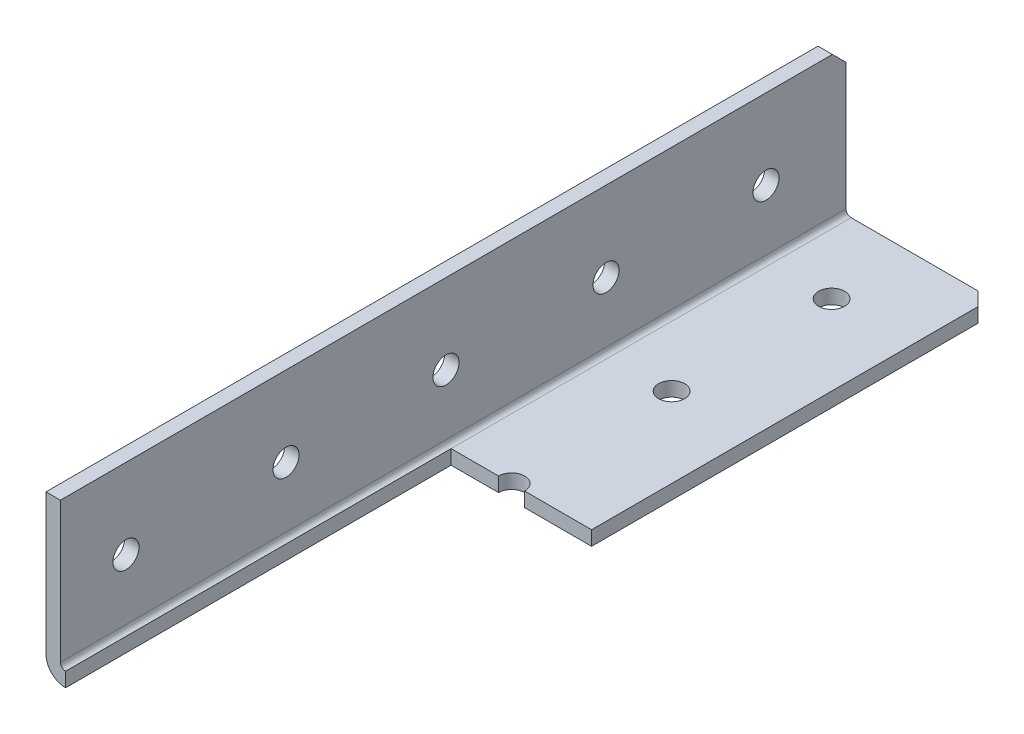
from build123d import *

# Parameters (mm, degrees)
SKETCH1_W                  = 25.4
SKETCH1_H                  = 1498.6
BOSS_EXTRUDE1_DEPTH        = 25.4
SKETCH2_W                  = 23.114
SKETCH2_H                  = 23.114
CUT_EXTRUDE1_DEPTH         = 1499.6
M3_5_CLEARANCE_HOLE1_D     = 4.1402
M3_5_CLEARANCE_HOLE1_DEPTH = 25.4
M3_5_CLEARANCE_HOLE2_D     = 4.1402
M3_5_CLEARANCE_HOLE2_DEPTH = 25.4
CHAMFER1_SIZE              = 2.159
FILLET1_R                  = 0.8128
FILLET2_R                  = 3.0988
SKETCH8_W                  = 95.882963774
SKETCH8_H                  = 79.338329604
CUT_EXTRUDE3_DEPTH         = 1371.6
SKETCH11_W                 = 51.462522779
SKETCH11_H                 = 66.676735099
CUT_EXTRUDE6_DEPTH         = 2.286
SKETCH12_W                 = 22.3012
SKETCH12_H                 = 61.214
CUT_EXTRUDE7_DEPTH         = 2.54


with BuildPart() as part:
    # Sketch1 → Boss-Extrude1 (new body)
    with BuildSketch(Plane(origin=(0, 0, 0), x_dir=(0, -1, 0), z_dir=(-1, 0, 0))):
        with Locations((-12.7, 0)):
            Rectangle(SKETCH1_W, SKETCH1_H)
    extrude(amount=-BOSS_EXTRUDE1_DEPTH)

    # Sketch2 → Cut-Extrude1 (cut, through all)
    with BuildSketch(Plane(origin=(0, 0, -749.3), x_dir=(-1, 0, 0), z_dir=(0, 0, -1))):
        with Locations((-13.843, 13.843)):
            Rectangle(SKETCH2_W, SKETCH2_H)
    extrude(amount=-CUT_EXTRUDE1_DEPTH, mode=Mode.SUBTRACT)

    # M3.5 Clearance Hole1
    with Locations(Plane(origin=(0, 0, 0), x_dir=(-1, 0, 0), z_dir=(0, -1, 0))):
        with Locations((-12.7, 736.6), (-12.7, 711.2), (-12.7, 685.8), (-12.7, 660.4), (-12.7, 635), (-12.7, 609.6), (-12.7, 584.2), (-12.7, 558.8), (-12.7, 533.4), (-12.7, 508), (-12.7, 482.6), (-12.7, 457.2), (-12.7, 431.8), (-12.7, 406.4), (-12.7, 381), (-12.7, 355.6), (-12.7, 330.2), (-12.7, 304.8), (-12.7, 279.4), (-12.7, 254), (-12.7, 228.6), (-12.7, 203.2), (-12.7, 177.8), (-12.7, 152.4), (-12.7, 127), (-12.7, 101.6), (-12.7, 76.2), (-12.7, 50.8), (-12.7, 25.4), (-12.7, 0), (-12.7, -25.4), (-12.7, -50.8), (-12.7, -76.2), (-12.7, -101.6), (-12.7, -127), (-12.7, -152.4), (-12.7, -177.8), (-12.7, -203.2), (-12.7, -228.6), (-12.7, -254), (-12.7, -279.4), (-12.7, -304.8), (-12.7, -330.2), (-12.7, -355.6), (-12.7, -381), (-12.7, -406.4), (-12.7, -431.8), (-12.7, -457.2), (-12.7, -482.6), (-12.7, -508), (-12.7, -533.4), (-12.7, -558.8), (-12.7, -584.2), (-12.7, -609.6), (-12.7, -635), (-12.7, -660.4), (-12.7, -685.8), (-12.7, -711.2), (-12.7, -736.6)):
            Hole(M3_5_CLEARANCE_HOLE1_D / 2, depth=M3_5_CLEARANCE_HOLE1_DEPTH)

    # M3.5 Clearance Hole2
    with Locations(Plane.ZY):
        with Locations((711.2, 12.7), (736.6, 12.7), (685.8, 12.7), (660.4, 12.7), (635, 12.7), (609.6, 12.7), (584.2, 12.7), (558.8, 12.7), (533.4, 12.7), (508, 12.7), (482.6, 12.7), (457.2, 12.7), (431.8, 12.7), (406.4, 12.7), (381, 12.7), (355.6, 12.7), (330.2, 12.7), (304.8, 12.7), (279.4, 12.7), (254, 12.7), (228.6, 12.7), (203.2, 12.7), (177.8, 12.7), (152.4, 12.7), (127, 12.7), (101.6, 12.7), (76.2, 12.7), (50.8, 12.7), (25.4, 12.7), (0, 12.7), (-25.4, 12.7), (-50.8, 12.7), (-76.2, 12.7), (-101.6, 12.7), (-127, 12.7), (-152.4, 12.7), (-177.8, 12.7), (-203.2, 12.7), (-228.6, 12.7), (-254, 12.7), (-279.4, 12.7), (-304.8, 12.7), (-330.2, 12.7), (-355.6, 12.7), (-381, 12.7), (-406.4, 12.7), (-431.8, 12.7), (-457.2, 12.7), (-482.6, 12.7), (-508, 12.7), (-533.4, 12.7), (-558.8, 12.7), (-584.2, 12.7), (-609.6, 12.7), (-635, 12.7), (-660.4, 12.7), (-685.8, 12.7), (-711.2, 12.7), (-736.6, 12.7)):
            Hole(M3_5_CLEARANCE_HOLE2_D / 2, depth=M3_5_CLEARANCE_HOLE2_DEPTH)

    # Chamfer1
    chamfer1_edges = [part.edges().sort_by_distance(p)[0] for p in [
        (25.4, 1.143, -749.3),
        (1.143, 25.4, 749.3),
        (1.143, 25.4, -749.3),
        (25.4, 1.143, 749.3),
    ]]
    chamfer(chamfer1_edges, length=CHAMFER1_SIZE)

    # Fillet1
    fillet1_edges = [part.edges().sort_by_distance(p)[0] for p in [
        (2.286, 2.286, 0),
    ]]
    fillet(fillet1_edges, radius=FILLET1_R)

    # Fillet2
    fillet2_edges = [part.edges().sort_by_distance(p)[0] for p in [
        (0, 0, 0),
    ]]
    fillet(fillet2_edges, radius=FILLET2_R)

    # Sketch8 → Cut-Extrude3 (cut)
    with BuildSketch(Plane.XY.offset(749.3)):
        with Locations((2.286, 3.0988)):
            Rectangle(SKETCH8_W, SKETCH8_H)
    extrude(amount=-CUT_EXTRUDE3_DEPTH, mode=Mode.SUBTRACT)

    # Sketch11 → Cut-Extrude6 (cut)
    with BuildSketch(Plane.XY.offset(-622.3)):
        with Locations((1.85517497, 1.74884985)):
            Rectangle(SKETCH11_W, SKETCH11_H)
    extrude(amount=-CUT_EXTRUDE6_DEPTH, mode=Mode.SUBTRACT)

    # Sketch12 → Cut-Extrude7 (cut)
    with BuildSketch(Plane(origin=(0, 2.286, 0), x_dir=(1, 0, 0), z_dir=(0, 1, 0))):
        with Locations((14.2494, 655.193)):
            Rectangle(SKETCH12_W, SKETCH12_H)
    extrude(amount=-CUT_EXTRUDE7_DEPTH, mode=Mode.SUBTRACT)


solid = part.part
